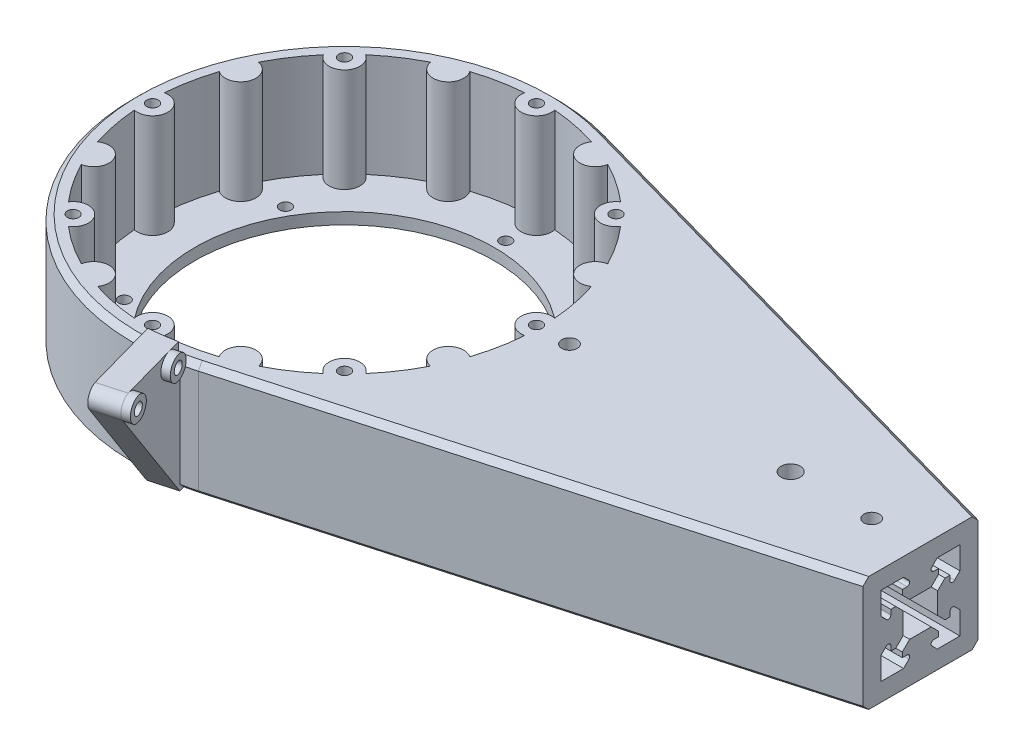
from build123d import *

# Parameters (mm, degrees)
SKETCH1_R                = 55
SKETCH1_R_2              = 39
SKETCH1_R_3              = 1.5
BOSS_EXTRUDE1_DEPTH      = 3
SKETCH2_R                = 55
SKETCH2_R_2              = 1.5
BOSS_EXTRUDE3_DEPTH      = 27
BOSS_EXTRUDE4_START      = -30
SKETCH3_R                = 2
SKETCH3_R_2              = 2.5
SKETCH3_R_3              = 1.5
BOSS_EXTRUDE4_DEPTH      = 30
CUT_EXTRUDE1_DEPTH       = 134
SKETCH10_W               = 7
SKETCH10_H               = 34
BOSS_EXTRUDE7_DEPTH      = 22
BOSS_EXTRUDE7_DEPTH_BACK = 2
SKETCH11_R               = 1.5
CUT_EXTRUDE5_DEPTH       = 20
SKETCH12_R               = 3
SKETCH12_R_2             = 1.5
BOSS_EXTRUDE10_DEPTH     = 2
SKETCH13_R               = 55.5
CUT_EXTRUDE6_DEPTH       = 172.304291715
CHAMFER1_SIZE            = 1.5


with BuildPart() as part:
    # Sketch1 → Boss-Extrude1 (new body)
    with BuildSketch(Plane(origin=(0, 0, 0), x_dir=(1, 0, 0), z_dir=(0, 1, 0))):
        with Locations(Location((0, 0, 0), (0, 0, 270))):
            Circle(SKETCH1_R)
        with Locations(Location((0, 0, 0), (0, 0, 270))):
            Circle(SKETCH1_R_2, mode=Mode.SUBTRACT)
        with Locations(Location((0, 50, 0), (0, 0, 270))):
            Circle(SKETCH1_R_3, mode=Mode.SUBTRACT)
        with Locations(Location((35.355339059, 35.355339059, 0), (0, 0, 270))):
            Circle(SKETCH1_R_3, mode=Mode.SUBTRACT)
        with Locations(Location((50, 0, 0), (0, 0, 270))):
            Circle(SKETCH1_R_3, mode=Mode.SUBTRACT)
        with Locations(Location((35.355339059, -35.355339059, 0), (0, 0, 270))):
            Circle(SKETCH1_R_3, mode=Mode.SUBTRACT)
        with Locations(Location((0, -50, 0), (0, 0, 270))):
            Circle(SKETCH1_R_3, mode=Mode.SUBTRACT)
        with Locations(Location((-35.355339059, -35.355339059, 0), (0, 0, 270))):
            Circle(SKETCH1_R_3, mode=Mode.SUBTRACT)
        with Locations(Location((-50, 0, 0), (0, 0, 270))):
            Circle(SKETCH1_R_3, mode=Mode.SUBTRACT)
        with Locations(Location((-35.355339059, 35.355339059, 0), (0, 0, 270))):
            Circle(SKETCH1_R_3, mode=Mode.SUBTRACT)
        with Locations(Location((0, 42, 0), (0, 0, 270))):
            Circle(SKETCH1_R_3, mode=Mode.SUBTRACT)
        with Locations(Location((36.373066959, 21, 0), (0, 0, 270))):
            Circle(SKETCH1_R_3, mode=Mode.SUBTRACT)
        with Locations(Location((36.373066959, -21, 0), (0, 0, 270))):
            Circle(SKETCH1_R_3, mode=Mode.SUBTRACT)
        with Locations(Location((0, -42, 0), (0, 0, 270))):
            Circle(SKETCH1_R_3, mode=Mode.SUBTRACT)
        with Locations(Location((-36.373066959, -21, 0), (0, 0, 270))):
            Circle(SKETCH1_R_3, mode=Mode.SUBTRACT)
        with Locations(Location((-36.373066959, 21, 0), (0, 0, 270))):
            Circle(SKETCH1_R_3, mode=Mode.SUBTRACT)
    extrude(amount=BOSS_EXTRUDE1_DEPTH)

    # Sketch2 → Boss-Extrude3 (add)
    with BuildSketch(Plane(origin=(0, 3, 0), x_dir=(1, 0, 0), z_dir=(0, 1, 0))):
        with Locations(Location((0, 0, 0), (0, 0, 270))):
            Circle(SKETCH2_R)
        with Locations(Location((-35.355339059, 35.355339059, 0), (0, 0, 270))):
            Circle(SKETCH2_R_2, mode=Mode.SUBTRACT)
        with Locations(Location((-50, 0, 0), (0, 0, 270))):
            Circle(SKETCH2_R_2, mode=Mode.SUBTRACT)
        with Locations(Location((-35.355339059, -35.355339059, 0), (0, 0, 270))):
            Circle(SKETCH2_R_2, mode=Mode.SUBTRACT)
        with Locations(Location((0, -50, 0), (0, 0, 270))):
            Circle(SKETCH2_R_2, mode=Mode.SUBTRACT)
        with Locations(Location((35.355339059, -35.355339059, 0), (0, 0, 270))):
            Circle(SKETCH2_R_2, mode=Mode.SUBTRACT)
        with Locations(Location((50, 0, 0), (0, 0, 270))):
            Circle(SKETCH2_R_2, mode=Mode.SUBTRACT)
        with Locations(Location((35.355339059, 35.355339059, 0), (0, 0, 270))):
            Circle(SKETCH2_R_2, mode=Mode.SUBTRACT)
        with Locations(Location((0, 50, 0), (0, 0, 270))):
            Circle(SKETCH2_R_2, mode=Mode.SUBTRACT)
        with BuildLine():
            ThreePointArc((-3.908644266, 50.85), (0, 46), (3.908644266, 50.85))
            ThreePointArc((3.908644266, 50.85), (9.949606423, 50.020049301), (15.848336098, 48.475047632))
            ThreePointArc((15.848336098, 48.475047632), (17.603437889, 42.498458496), (23.070568973, 45.483500825))
            ThreePointArc((23.070568973, 45.483500825), (28.334081884, 42.404950227), (33.192550957, 38.720208689))
            ThreePointArc((33.192550957, 38.720208689), (32.526911935, 32.526911935), (38.720208689, 33.192550957))
            ThreePointArc((38.720208689, 33.192550957), (42.404950227, 28.334081884), (45.483500825, 23.070568973))
            ThreePointArc((45.483500825, 23.070568973), (42.498458496, 17.603437889), (48.475047632, 15.848336098))
            ThreePointArc((48.475047632, 15.848336098), (50.020049301, 9.949606423), (50.85, 3.908644266))
            ThreePointArc((50.85, 3.908644266), (46, 0), (50.85, -3.908644266))
            ThreePointArc((50.85, -3.908644266), (50.020049301, -9.949606423), (48.475047632, -15.848336098))
            ThreePointArc((48.475047632, -15.848336098), (42.498458496, -17.603437889), (45.483500825, -23.070568973))
            ThreePointArc((45.483500825, -23.070568973), (42.404950227, -28.334081884), (38.720208689, -33.192550957))
            ThreePointArc((38.720208689, -33.192550957), (32.526911935, -32.526911935), (33.192550957, -38.720208689))
            ThreePointArc((33.192550957, -38.720208689), (28.334081884, -42.404950227), (23.070568973, -45.483500825))
            ThreePointArc((23.070568973, -45.483500825), (17.603437889, -42.498458496), (15.848336098, -48.475047632))
            ThreePointArc((15.848336098, -48.475047632), (9.949606423, -50.020049301), (3.908644266, -50.85))
            ThreePointArc((3.908644266, -50.85), (0, -46), (-3.908644266, -50.85))
            ThreePointArc((-3.908644266, -50.85), (-9.949606423, -50.020049301), (-15.848336098, -48.475047632))
            ThreePointArc((-15.848336098, -48.475047632), (-17.603437889, -42.498458496), (-23.070568973, -45.483500825))
            ThreePointArc((-23.070568973, -45.483500825), (-28.334081884, -42.404950227), (-33.192550957, -38.720208689))
            ThreePointArc((-33.192550957, -38.720208689), (-32.526911935, -32.526911935), (-38.720208689, -33.192550957))
            ThreePointArc((-38.720208689, -33.192550957), (-42.404950227, -28.334081884), (-45.483500825, -23.070568973))
            ThreePointArc((-45.483500825, -23.070568973), (-42.498458496, -17.603437889), (-48.475047632, -15.848336098))
            ThreePointArc((-48.475047632, -15.848336098), (-50.020049301, -9.949606423), (-50.85, -3.908644266))
            ThreePointArc((-50.85, -3.908644266), (-46, 0), (-50.85, 3.908644266))
            ThreePointArc((-50.85, 3.908644266), (-50.020049301, 9.949606423), (-48.475047632, 15.848336098))
            ThreePointArc((-48.475047632, 15.848336098), (-42.498458496, 17.603437889), (-45.483500825, 23.070568973))
            ThreePointArc((-45.483500825, 23.070568973), (-42.404950227, 28.334081884), (-38.720208689, 33.192550957))
            ThreePointArc((-38.720208689, 33.192550957), (-32.526911935, 32.526911935), (-33.192550957, 38.720208689))
            ThreePointArc((-33.192550957, 38.720208689), (-28.334081884, 42.404950227), (-23.070568973, 45.483500825))
            ThreePointArc((-23.070568973, 45.483500825), (-17.603437889, 42.498458496), (-15.848336098, 48.475047632))
            ThreePointArc((-15.848336098, 48.475047632), (-9.949606423, 50.020049301), (-3.908644266, 50.85))
        make_face(mode=Mode.SUBTRACT)
    extrude(amount=BOSS_EXTRUDE3_DEPTH)

    # Sketch3 → Boss-Extrude4 (add)
    with BuildSketch(Plane(origin=(0, 30, 0), x_dir=(1, 0, 0), z_dir=(0, 1, 0)).offset(BOSS_EXTRUDE4_START)):
        with BuildLine():
            Line((150, 15), (14.871539362, 52.951273044))
            ThreePointArc((14.871539362, 52.951273044), (43.834544967, 33.21946218), (55, 0))
            ThreePointArc((55, 0), (43.834544967, -33.21946218), (14.871539362, -52.951273044))
            Line((14.871539362, -52.951273044), (150, -15))
            Line((150, -15), (150, 15))
        make_face()
        with Locations(Location((58.6, 0, 0), (0, 0, 270))):
            Circle(SKETCH3_R, mode=Mode.SUBTRACT)
        with Locations(Location((116.2, 0, 0), (0, 0, 270))):
            Circle(SKETCH3_R_2, mode=Mode.SUBTRACT)
        with Locations(Location((137.3, 0, 0), (0, 0, 270))):
            Circle(SKETCH3_R, mode=Mode.SUBTRACT)
        with BuildLine():
            ThreePointArc((55, 0), (43.834544967, 33.21946218), (14.871539362, 52.951273044))
            ThreePointArc((14.871539362, 52.951273044), (-55, 0), (14.871539362, -52.951273044))
            ThreePointArc((14.871539362, -52.951273044), (43.834544967, -33.21946218), (55, 0))
        make_face()
        with Locations(Location((-35.355339059, -35.355339059, 0), (0, 0, 270))):
            Circle(SKETCH3_R_3, mode=Mode.SUBTRACT)
        with Locations(Location((0, -50, 0), (0, 0, 270))):
            Circle(SKETCH3_R_3, mode=Mode.SUBTRACT)
        with Locations(Location((35.355339059, -35.355339059, 0), (0, 0, 270))):
            Circle(SKETCH3_R_3, mode=Mode.SUBTRACT)
        with Locations(Location((-50, 0, 0), (0, 0, 270))):
            Circle(SKETCH3_R_3, mode=Mode.SUBTRACT)
        with BuildLine():
            ThreePointArc((-38.720208689, -33.192550957), (-42.404950227, -28.334081884), (-45.483500825, -23.070568973))
            ThreePointArc((-45.483500825, -23.070568973), (-42.498458496, -17.603437889), (-48.475047632, -15.848336098))
            ThreePointArc((-48.475047632, -15.848336098), (-50.020049301, -9.949606423), (-50.85, -3.908644266))
            ThreePointArc((-50.85, -3.908644266), (-46, 0), (-50.85, 3.908644266))
            ThreePointArc((-50.85, 3.908644266), (-50.020049301, 9.949606423), (-48.475047632, 15.848336098))
            ThreePointArc((-48.475047632, 15.848336098), (-42.498458496, 17.603437889), (-45.483500825, 23.070568973))
            ThreePointArc((-45.483500825, 23.070568973), (-42.404950227, 28.334081884), (-38.720208689, 33.192550957))
            ThreePointArc((-38.720208689, 33.192550957), (-32.526911935, 32.526911935), (-33.192550957, 38.720208689))
            ThreePointArc((-33.192550957, 38.720208689), (-28.334081884, 42.404950227), (-23.070568973, 45.483500825))
            ThreePointArc((-23.070568973, 45.483500825), (-17.603437889, 42.498458496), (-15.848336098, 48.475047632))
            ThreePointArc((-15.848336098, 48.475047632), (-9.949606423, 50.020049301), (-3.908644266, 50.85))
            ThreePointArc((-3.908644266, 50.85), (0, 46), (3.908644266, 50.85))
            ThreePointArc((3.908644266, 50.85), (9.949606423, 50.020049301), (15.848336098, 48.475047632))
            ThreePointArc((15.848336098, 48.475047632), (17.603437889, 42.498458496), (23.070568973, 45.483500825))
            ThreePointArc((23.070568973, 45.483500825), (28.334081884, 42.404950227), (33.192550957, 38.720208689))
            ThreePointArc((33.192550957, 38.720208689), (32.526911935, 32.526911935), (38.720208689, 33.192550957))
            ThreePointArc((38.720208689, 33.192550957), (42.404950227, 28.334081884), (45.483500825, 23.070568973))
            ThreePointArc((45.483500825, 23.070568973), (42.498458496, 17.603437889), (48.475047632, 15.848336098))
            ThreePointArc((48.475047632, 15.848336098), (50.020049301, 9.949606423), (50.85, 3.908644266))
            ThreePointArc((50.85, 3.908644266), (46, 0), (50.85, -3.908644266))
            ThreePointArc((50.85, -3.908644266), (50.020049301, -9.949606423), (48.475047632, -15.848336098))
            ThreePointArc((48.475047632, -15.848336098), (42.498458496, -17.603437889), (45.483500825, -23.070568973))
            ThreePointArc((45.483500825, -23.070568973), (42.404950227, -28.334081884), (38.720208689, -33.192550957))
            ThreePointArc((38.720208689, -33.192550957), (32.526911935, -32.526911935), (33.192550957, -38.720208689))
            ThreePointArc((33.192550957, -38.720208689), (28.334081884, -42.404950227), (23.070568973, -45.483500825))
            ThreePointArc((23.070568973, -45.483500825), (17.603437889, -42.498458496), (15.848336098, -48.475047632))
            ThreePointArc((15.848336098, -48.475047632), (9.949606423, -50.020049301), (3.908644266, -50.85))
            ThreePointArc((3.908644266, -50.85), (0, -46), (-3.908644266, -50.85))
            ThreePointArc((-3.908644266, -50.85), (-9.949606423, -50.020049301), (-15.848336098, -48.475047632))
            ThreePointArc((-15.848336098, -48.475047632), (-17.603437889, -42.498458496), (-23.070568973, -45.483500825))
            ThreePointArc((-23.070568973, -45.483500825), (-28.334081884, -42.404950227), (-33.192550957, -38.720208689))
            ThreePointArc((-33.192550957, -38.720208689), (-32.526911935, -32.526911935), (-38.720208689, -33.192550957))
        make_face(mode=Mode.SUBTRACT)
        with Locations(Location((-35.355339059, 35.355339059, 0), (0, 0, 270))):
            Circle(SKETCH3_R_3, mode=Mode.SUBTRACT)
        with Locations(Location((35.355339059, 35.355339059, 0), (0, 0, 270))):
            Circle(SKETCH3_R_3, mode=Mode.SUBTRACT)
        with Locations(Location((0, 50, 0), (0, 0, 270))):
            Circle(SKETCH3_R_3, mode=Mode.SUBTRACT)
        with Locations(Location((50, 0, 0), (0, 0, 270))):
            Circle(SKETCH3_R_3, mode=Mode.SUBTRACT)
    extrude(amount=BOSS_EXTRUDE4_DEPTH)

    # Sketch4 → Cut-Extrude1 (cut)
    with BuildSketch(Plane(origin=(150, 0, 0), x_dir=(0, 0, -1), z_dir=(1, 0, 0))):
        with BuildLine():
            Line((2.802943725, 19.5), (-2.802943725, 19.5))
            Line((-2.802943725, 19.5), (-4.710050506, 21.407106781))
            Line((-4.710050506, 21.407106781), (-4.710050506, 22.7))
            Line((-4.710050506, 22.7), (-3.482842712, 22.7))
            ThreePointArc((-3.482842712, 22.7), (-2.83612704, 23.132121597), (-2.987867966, 23.894974747))
            Line((-2.987867966, 23.894974747), (-4.387867966, 25.294974747))
            Line((-4.387867966, 25.294974747), (-10.294974747, 25.294974747))
            Line((-10.294974747, 25.294974747), (-10.294974747, 19.387867966))
            Line((-10.294974747, 19.387867966), (-8.894974747, 17.987867966))
            ThreePointArc((-8.894974747, 17.987867966), (-8.132121597, 17.83612704), (-7.7, 18.482842712))
            Line((-7.7, 18.482842712), (-7.7, 19.710050506))
            Line((-7.7, 19.710050506), (-6.407106781, 19.710050506))
            Line((-6.407106781, 19.710050506), (-4.5, 17.802943725))
            Line((-4.5, 17.802943725), (-4.5, 12.197056275))
            Line((-4.5, 12.197056275), (-6.407106781, 10.289949494))
            Line((-6.407106781, 10.289949494), (-7.7, 10.289949494))
            Line((-7.7, 10.289949494), (-7.7, 11.517157288))
            ThreePointArc((-7.7, 11.517157288), (-8.132121597, 12.16387296), (-8.894974747, 12.012132034))
            Line((-8.894974747, 12.012132034), (-10.294974747, 10.612132034))
            Line((-10.294974747, 10.612132034), (-10.294974747, 4.705025253))
            Line((-10.294974747, 4.705025253), (-4.387867966, 4.705025253))
            Line((-4.387867966, 4.705025253), (-2.987867966, 6.105025253))
            ThreePointArc((-2.987867966, 6.105025253), (-2.83612704, 6.867878403), (-3.482842712, 7.3))
            Line((-3.482842712, 7.3), (-4.710050506, 7.3))
            Line((-4.710050506, 7.3), (-4.710050506, 8.592893219))
            Line((-4.710050506, 8.592893219), (-2.802943725, 10.5))
            Line((-2.802943725, 10.5), (2.802943725, 10.5))
            Line((2.802943725, 10.5), (4.710050506, 8.592893219))
            Line((4.710050506, 8.592893219), (4.710050506, 7.3))
            Line((4.710050506, 7.3), (3.482842712, 7.3))
            ThreePointArc((3.482842712, 7.3), (2.83612704, 6.867878403), (2.987867966, 6.105025253))
            Line((2.987867966, 6.105025253), (4.387867966, 4.705025253))
            Line((4.387867966, 4.705025253), (10.294974747, 4.705025253))
            Line((10.294974747, 4.705025253), (10.294974747, 10.612132034))
            Line((10.294974747, 10.612132034), (8.894974747, 12.012132034))
            ThreePointArc((8.894974747, 12.012132034), (8.132121597, 12.16387296), (7.7, 11.517157288))
            Line((7.7, 11.517157288), (7.7, 10.289949494))
            Line((7.7, 10.289949494), (6.407106781, 10.289949494))
            Line((6.407106781, 10.289949494), (4.5, 12.197056275))
            Line((4.5, 12.197056275), (4.5, 17.802943725))
            Line((4.5, 17.802943725), (6.407106781, 19.710050506))
            Line((6.407106781, 19.710050506), (7.7, 19.710050506))
            Line((7.7, 19.710050506), (7.7, 18.482842712))
            ThreePointArc((7.7, 18.482842712), (8.132121597, 17.83612704), (8.894974747, 17.987867966))
            Line((8.894974747, 17.987867966), (10.294974747, 19.387867966))
            Line((10.294974747, 19.387867966), (10.294974747, 25.294974747))
            Line((10.294974747, 25.294974747), (4.387867966, 25.294974747))
            Line((4.387867966, 25.294974747), (2.987867966, 23.894974747))
            ThreePointArc((2.987867966, 23.894974747), (2.83612704, 23.132121597), (3.482842712, 22.7))
            Line((3.482842712, 22.7), (4.710050506, 22.7))
            Line((4.710050506, 22.7), (4.710050506, 21.407106781))
            Line((4.710050506, 21.407106781), (2.802943725, 19.5))
        make_face()
    extrude(amount=-CUT_EXTRUDE1_DEPTH, mode=Mode.SUBTRACT)

    # Sketch10 → Boss-Extrude7 (add, two sides)
    with BuildSketch(Plane(origin=(14.871539362, 0, 52.951273044), x_dir=(0.9627504189846997, 0, -0.2703916247681967), z_dir=(0.2703916247681967, 0, 0.9627504189846997))) as boss_extrude7_sk:
        with Locations((-7.5, 17)):
            Rectangle(SKETCH10_W, SKETCH10_H)
    extrude(amount=BOSS_EXTRUDE7_DEPTH)
    extrude(boss_extrude7_sk.sketch, amount=-BOSS_EXTRUDE7_DEPTH_BACK)

    # Sketch11 → Cut-Extrude5 (cut)
    with BuildSketch(Plane(origin=(-3.851001676, 0, 1.081566499), x_dir=(-0.27039162476819667, 0, -0.9627504189846997), z_dir=(0.9627504189846998, 0, -0.27039162476819667))):
        with BuildLine():
            Line((-77, 0), (-54.854352608, 0))
            Line((-54.854352608, 0), (-76.413310652, 29.229920746))
            ThreePointArc((-76.413310652, 29.229920746), (-76.84861671, 30.073008136), (-76.998728294, 31.009893519))
            Line((-76.998728294, 31.009893519), (-77, 0))
        make_face()
        with BuildLine():
            Line((-77, 34), (-76.998728294, 31.009893519))
            ThreePointArc((-76.998728294, 31.009893519), (-76.199293063, 33.048393312), (-74.227232515, 34))
            Line((-74.227232515, 34), (-77, 34))
        make_face()
        with Locations((-74, 31.009893519)):
            Circle(SKETCH11_R)
        with Locations((-59, 31.009893519)):
            Circle(SKETCH11_R)
    extrude(amount=-CUT_EXTRUDE5_DEPTH, mode=Mode.SUBTRACT)


with BuildPart() as cut_extrude5_kept_piece:
    # of the separate pieces the step leaves, the one the design keeps (cut_extrude5_pieces_kept)
    add(part.part.solids().sort_by_distance((14.871539362, 30, 52.951273044))[0])

    # Sketch12 → Boss-Extrude10 (add)
    with BuildSketch(Plane(origin=(-3.851001676, 0, 1.081566499), x_dir=(-0.27039162476819667, 0, -0.9627504189846997), z_dir=(0.9627504189846998, 0, -0.27039162476819667))):
        with Locations(Location((-74, 31.009893519, 0), (0, 0, 218.079520443))):
            Circle(SKETCH12_R)
        with Locations((-74, 31.009893519)):
            Circle(SKETCH12_R_2, mode=Mode.SUBTRACT)
        with Locations(Location((-59, 31.009893519, 0), (0, 0, 94.654487138))):
            Circle(SKETCH12_R)
        with Locations((-59, 31.009893519)):
            Circle(SKETCH12_R_2, mode=Mode.SUBTRACT)
    extrude(amount=BOSS_EXTRUDE10_DEPTH)

    # Sketch13 → Cut-Extrude6 (cut, through all)
    with BuildSketch(Plane(origin=(0, 30, 0), x_dir=(1, 0, 0), z_dir=(0, 1, 0))):
        Circle(SKETCH13_R)
    extrude(amount=CUT_EXTRUDE6_DEPTH, mode=Mode.SUBTRACT)

    # Chamfer1
    chamfer1_edges = [cut_extrude5_kept_piece.edges().sort_by_distance(p)[0] for p in [
        (12.934913791, 30, 53.457347533),
        (82.435769681, 30, 33.975636522),
        (-54.721488415, 30, -5.52799291),
        (82.435769681, 0, 33.975636522),
        (82.435769681, 30, -33.975636522),
        (-54.721488415, 0, -5.52799291),
        (12.934913791, 0, 53.457347533),
        (82.435769681, 0, -33.975636522),
    ]]
    chamfer(chamfer1_edges, length=CHAMFER1_SIZE)


solid = cut_extrude5_kept_piece.part
